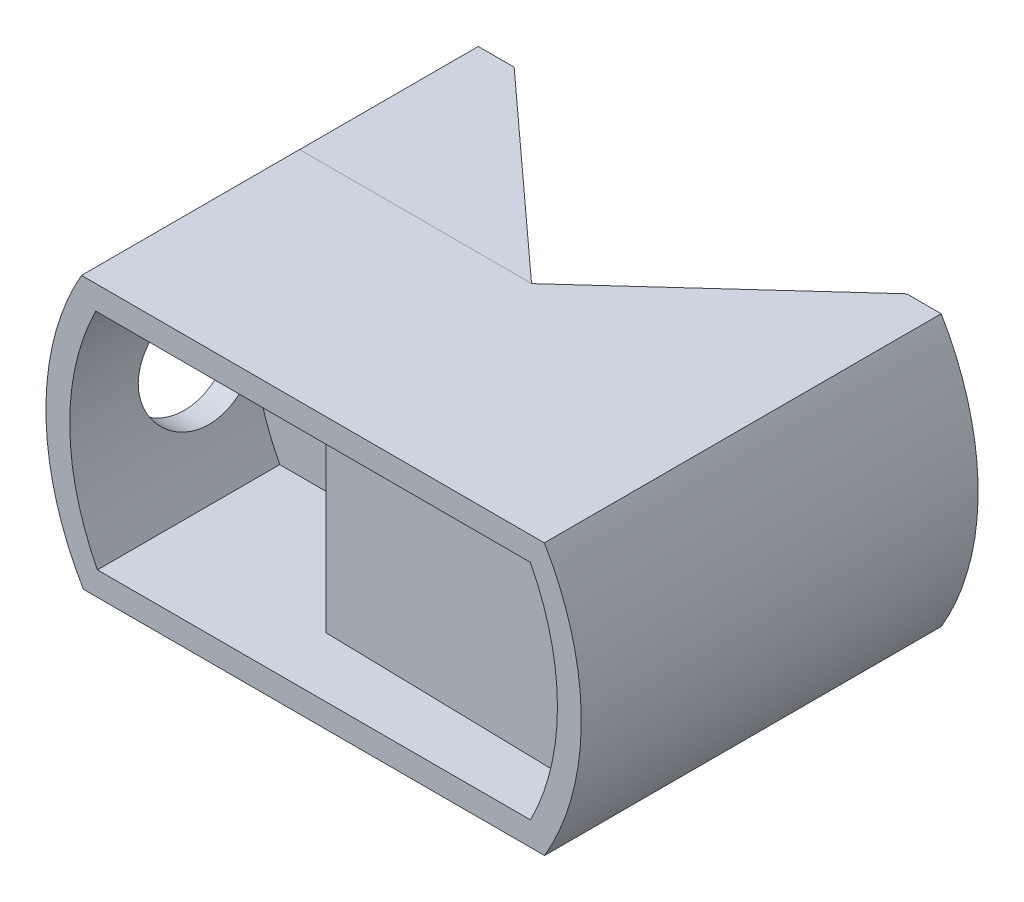
from build123d import *

# Parameters (mm, degrees)
BOSS_EXTRUDE1_DEPTH = 15.295
CUT_EXTRUDE1_DEPTH  = 206.919868261
FLOOR_START         = 3
FLOOR_2_DEPTH       = 3
BOSS_EXTRUDE4_START = 10.775
BOSS_EXTRUDE4_DEPTH = 10.775
BOSS_EXTRUDE5_REACH = 176.665
CUT_EXTRUDE3_REACH  = 209.578
SKETCH7_R           = 5.25
SKETCH14_OUTSIDE_W  = 59.009
SKETCH14_OUTSIDE_H  = 36.805
CUT_EXTRUDE4_DEPTH  = 33.295


with BuildPart() as part:
    # Sketch1 → Boss-Extrude1 (new body)
    with BuildSketch(Plane(origin=(0, 0, -12.295), x_dir=(-1, 0, 0), z_dir=(0, 0, -1))):
        with BuildLine():
            Line((-169.369133898, -111.490025098), (-130.678433581, -111.48937301))
            ThreePointArc((-130.678433581, -111.48937301), (-127.534095849, -100.145401406), (-130.522109497, -88.759255177))
            Line((-130.522109497, -88.759255177), (-169.350721063, -88.778648203))
            ThreePointArc((-169.350721063, -88.778648203), (-172.450070697, -100.131831373), (-169.369133898, -111.490025098))
        make_face()
    extrude(amount=-BOSS_EXTRUDE1_DEPTH)

    # Sketch2 → Cut-Extrude1 (cut, through all)
    with BuildSketch(Plane.XY.offset(3)):
        with BuildLine():
            Line((168.171133654, -90.778059306), (131.717568579, -90.759852501))
            ThreePointArc((131.717568579, -90.759852501), (129.534116109, -100.141151153), (131.855022492, -109.48939284))
            Line((131.855022492, -109.48939284), (168.187605365, -109.490005184))
            ThreePointArc((168.187605365, -109.490005184), (170.450070154, -100.132033398), (168.171133654, -90.778059306))
        make_face()
    extrude(amount=-CUT_EXTRUDE1_DEPTH, mode=Mode.SUBTRACT)

    # Sketch4 → floor 2 (add)
    with BuildSketch(Plane(origin=(0, 0, -12.295), x_dir=(-1, 0, 0), z_dir=(0, 0, -1)).offset(FLOOR_START)):
        with BuildLine():
            Line((-169.369133898, -111.490025098), (-130.678433581, -111.48937301))
            ThreePointArc((-130.678433581, -111.48937301), (-127.534095849, -100.145401406), (-130.522109497, -88.759255177))
            Line((-130.522109497, -88.759255177), (-169.350721063, -88.778648203))
            ThreePointArc((-169.350721063, -88.778648203), (-172.450070697, -100.131831373), (-169.369133898, -111.490025098))
        make_face()
    extrude(amount=-FLOOR_2_DEPTH)

    # Sketch6 → Boss-Extrude4 (add)
    with BuildSketch(Plane.XY.offset(-12.295).offset(BOSS_EXTRUDE4_START)):
        with BuildLine():
            Line((146.5, -90.767235615), (146.5, -108.989639664))
            Line((146.5, -108.989639664), (168.187605365, -109.490005184))
            ThreePointArc((168.187605365, -109.490005184), (170.450070154, -100.132033398), (168.171133654, -90.778059306))
            Line((168.171133654, -90.778059306), (146.5, -90.767235615))
        make_face()
    extrude(amount=-BOSS_EXTRUDE4_DEPTH)

    # Boss-Extrude5: up to this face of the body (flat: up to its plane)
    boss_extrude5_end = Plane(part.part.faces().sort_by_distance((150.023783739, -111.489699054, -6.1475))[0])
    # Sketch11 → Boss-Extrude5 (add, up to the picked face)
    with BuildSketch(Plane(origin=(-0.044298414, -88.694043528, 0), x_dir=(0.9999998752738909, -0.0004994519023308322, 0), z_dir=(0.0004994519023308322, 0.9999998752738909, 0)), mode=Mode.PRIVATE) as boss_extrude5_sk1:
        Polygon((150.03815576, 15.295), (166.500079456, 30.295), (172.500079456, 30.295), (172.500079456, 15.295), align=None)
    boss_extrude5_tool1 = split(extrude(boss_extrude5_sk1.sketch, amount=-BOSS_EXTRUDE5_REACH, mode=Mode.PRIVATE), bisect_by=boss_extrude5_end, keep=Keep.BOTH, mode=Mode.PRIVATE)
    boss_extrude5 = boss_extrude5_tool1.solids().sort_by(Axis((164.546837, -88.776249, -21.34904), (-0.0004994519023308322, -0.9999998752738909, 0)))[0]
    add(boss_extrude5)

    # Cut-Extrude3: up to this face of the body (flat: up to its plane)
    cut_extrude3_end = Plane(part.part.faces().sort_by_distance((146.5, -99.87843764, -6.9075))[0])
    # Sketch7 → Cut-Extrude3 (cut, up to the picked face)
    with BuildSketch(Plane(origin=(0, 0, 0), x_dir=(0, 0, -1), z_dir=(1, 0, 0)), mode=Mode.PRIVATE) as cut_extrude3_sk1:
        with Locations(Location((7.995, -100, 0), (0, 0, 180))):
            Circle(SKETCH7_R)
    cut_extrude3_tool1 = split(extrude(cut_extrude3_sk1.sketch, amount=CUT_EXTRUDE3_REACH, mode=Mode.PRIVATE), bisect_by=cut_extrude3_end, keep=Keep.BOTH, mode=Mode.PRIVATE)
    add(cut_extrude3_tool1.solids().sort_by(Axis((0, -100, -7.995), (1, 0, 0)))[0], mode=Mode.SUBTRACT)

    # Mirror1: Boss-Extrude5 across plane
    add(boss_extrude5.mirror(Plane(origin=(149.98984246, -0.002527909, 0), x_dir=(0, 0, 1), z_dir=(-0.9999999998579736, 1.6853871084051315e-05, 0))))

    # Sketch14 outside → Cut-Extrude4 (cut)
    with BuildSketch(Plane.XY.offset(3)):
        with Locations((149.9885, -100.1245)):
            Rectangle(SKETCH14_OUTSIDE_W, SKETCH14_OUTSIDE_H)
        with BuildLine():
            Line((169.350721063, -88.778648203), (130.522109497, -88.759255177))
            ThreePointArc((130.522109497, -88.759255177), (127.534095849, -100.145401406), (130.678433581, -111.48937301))
            Line((130.678433581, -111.48937301), (169.369133898, -111.490025098))
            ThreePointArc((169.369133898, -111.490025098), (172.450070697, -100.131831373), (169.350721063, -88.778648203))
        make_face(mode=Mode.SUBTRACT)
    extrude(amount=-CUT_EXTRUDE4_DEPTH, mode=Mode.SUBTRACT)


with BuildPart() as part_1:
    # Body-Move/Copy1: moved
    add(part.part.moved(Location((-149.988154595, 100.149527643, 15.295))))


solid = part_1.part
